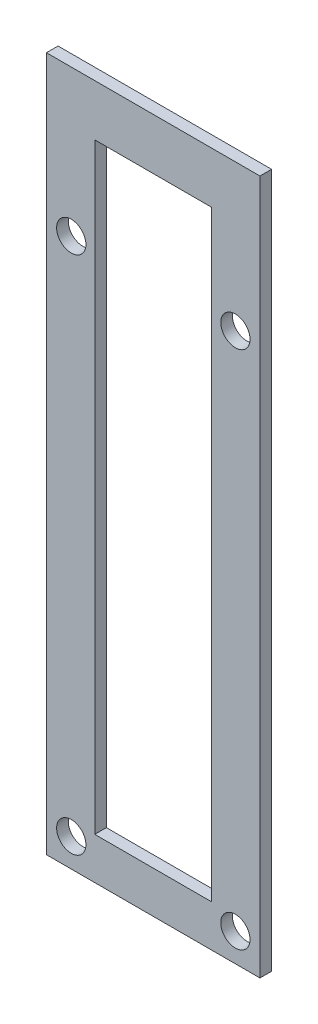
from build123d import *

# Parameters (mm, degrees)
BOSS_EXTRUDE1_DEPTH = 1.5875
BOSS_EXTRUDE2_REACH = 24.56
SKETCH3_W           = 1.5875
SKETCH3_H           = 7.003924561
SKETCH4_R           = 2
CUT_EXTRUDE1_DEPTH  = 15
SKETCH5_R           = 2
BOSS_EXTRUDE3_DEPTH = 1.5875


with BuildPart() as part:
    # Sketch2 → Boss-Extrude1 (new body)
    with BuildSketch(Plane.XY):
        Polygon((0, 0), (0, 94.86), (-6.6, 94.86), (-6.6, 5.71), (-22.56, 5.71), (-22.56, 94.86), (-29.16, 94.86), (-29.16, 0), align=None)
    extrude(amount=BOSS_EXTRUDE1_DEPTH)

    # Sketch3 → Boss-Extrude2 (add, up to next)
    with BuildSketch(Plane(origin=(-22.56, 0, 0), x_dir=(0, 0, -1), z_dir=(1, 0, 0)), mode=Mode.PRIVATE) as boss_extrude2_sk1:
        with Locations((-0.79375, 91.35803772)):
            Rectangle(SKETCH3_W, SKETCH3_H)
    boss_extrude2_tool1 = extrude(boss_extrude2_sk1.sketch, amount=BOSS_EXTRUDE2_REACH, mode=Mode.PRIVATE) - part.part
    add(boss_extrude2_tool1.solids().sort_by_distance((-22.56, 91.358038, 0.79375))[0])

    # Sketch4 → Cut-Extrude1 (cut)
    with BuildSketch(Plane.XY.offset(1.5875)):
        with Locations((-3.354353393, 47.428062363)):
            Circle(SKETCH4_R)
        with Locations((-25.771024386, 47.428062363)):
            Circle(SKETCH4_R)
        with Locations((-25.771024386, 3.86)):
            Circle(SKETCH4_R)
        with Locations((-3.354353393, 3.86)):
            Circle(SKETCH4_R)
        with Locations((-25.771024386, 74.86)):
            Circle(SKETCH4_R)
        with Locations((-3.354353393, 74.86)):
            Circle(SKETCH4_R)
    extrude(amount=-CUT_EXTRUDE1_DEPTH, mode=Mode.SUBTRACT)

    # Sketch5 → Boss-Extrude3 (add)
    with BuildSketch(Plane.XY.offset(1.5875)):
        with Locations((-25.771024386, 47.428062363)):
            Circle(SKETCH5_R)
        with Locations((-3.354353393, 47.428062363)):
            Circle(SKETCH5_R)
    extrude(amount=-BOSS_EXTRUDE3_DEPTH)


solid = part.part
